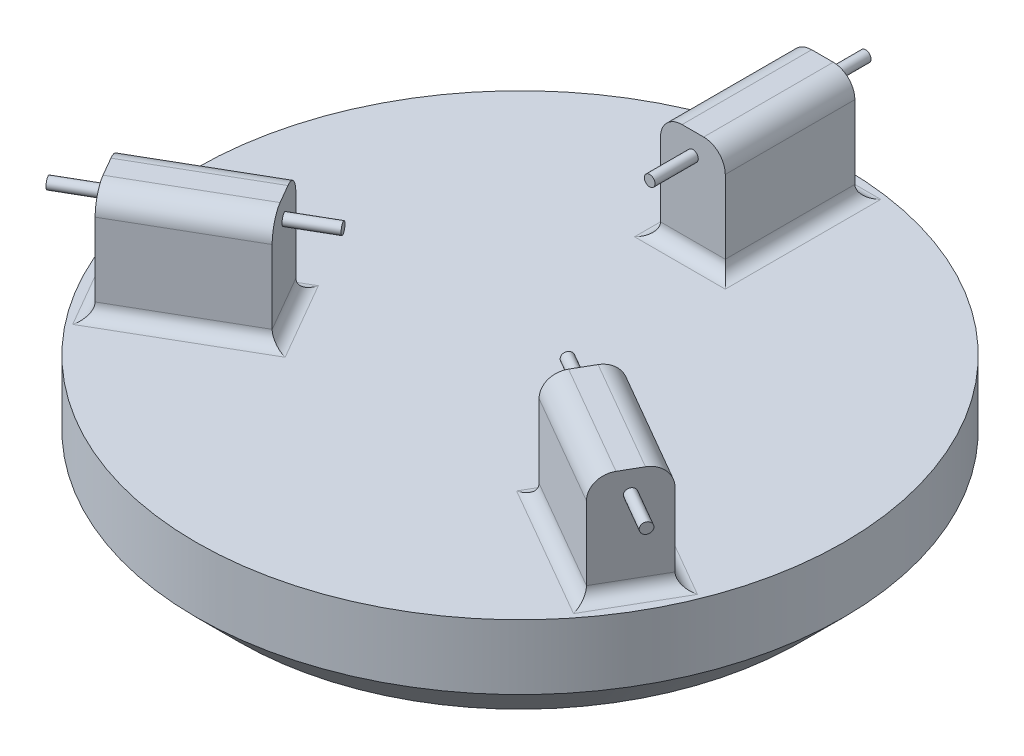
from build123d import *

# Parameters (mm, degrees)
SKETCH1_R           = 75
BOSS_EXTRUDE1_DEPTH = 25
SKETCH2_W           = 15
SKETCH2_H           = 30
BOSS_EXTRUDE2_DEPTH = 25
FILLET1_R           = 3
FILLET2_R           = 5
SKETCH3_R           = 1.25
BOSS_EXTRUDE3_DEPTH = 10
SKETCH4_R           = 1.25
BOSS_EXTRUDE4_DEPTH = 10
SKETCH5_R           = 1.25
BOSS_EXTRUDE5_DEPTH = 10
SKETCH6_R           = 1.25
BOSS_EXTRUDE6_DEPTH = 10
SKETCH7_R           = 1.25
BOSS_EXTRUDE7_DEPTH = 10
SKETCH8_R           = 1.25
BOSS_EXTRUDE8_DEPTH = 10
CHAMFER1_SIZE       = 10


with BuildPart() as part:
    # Sketch1 → Boss-Extrude1 (new body)
    with BuildSketch(Plane(origin=(0, 0, 0), x_dir=(1, 0, 0), z_dir=(0, 1, 0))):
        Circle(SKETCH1_R)
    extrude(amount=BOSS_EXTRUDE1_DEPTH)

    # Sketch2 → Boss-Extrude2 (add)
    with BuildSketch(Plane(origin=(0, 25, 0), x_dir=(1, 0, 0), z_dir=(0, 1, 0))):
        Polygon((-64.371778265, -28.504809472), (-56.871778265, -41.495190528), (-30.891016151, -26.495190528), (-38.391016151, -13.504809472), align=None)
        with Locations((0, 55)):
            Rectangle(SKETCH2_W, SKETCH2_H)
        Polygon((64.371778265, -28.504809472), (56.871778265, -41.495190528), (30.891016151, -26.495190528), (38.391016151, -13.504809472), align=None)
    extrude(amount=BOSS_EXTRUDE2_DEPTH)

    # Fillet1
    fillet1_edges = [part.edges().sort_by_distance(p)[0] for p in [
        (-7.5, 25, -55),
        (0, 25, -40),
        (7.5, 25, -55),
        (0, 25, -70),
        (51.381397208, 25, 21.004809472),
        (34.641016151, 25, 20),
        (43.881397208, 25, 33.995190528),
        (60.621778265, 25, 35),
        (-51.381397208, 25, 21.004809472),
        (-60.621778265, 25, 35),
        (-43.881397208, 25, 33.995190528),
        (-34.641016151, 25, 20),
    ]]
    fillet(fillet1_edges, radius=FILLET1_R)

    # Fillet2
    fillet2_edges = [part.edges().sort_by_distance(p)[0] for p in [
        (-7.5, 50, -55),
        (7.5, 50, -55),
        (51.381397208, 50, 21.004809472),
        (43.881397208, 50, 33.995190528),
        (-51.381397208, 50, 21.004809472),
        (-43.881397208, 50, 33.995190528),
    ]]
    fillet(fillet2_edges, radius=FILLET2_R)

    # Sketch3 → Boss-Extrude3 (add)
    with BuildSketch(Plane(origin=(60.621778265, 0, 35), x_dir=(0.5, 0, -0.866025404), z_dir=(0.866025404, 0, 0.5))):
        with Locations((0, 45)):
            Circle(SKETCH3_R)
    extrude(amount=BOSS_EXTRUDE3_DEPTH)

    # Sketch4 → Boss-Extrude4 (add)
    with BuildSketch(Plane(origin=(34.641016151, 0, 20), x_dir=(-0.5, 0, 0.866025404), z_dir=(-0.866025404, 0, -0.5))):
        with Locations((0, 45)):
            Circle(SKETCH4_R)
    extrude(amount=BOSS_EXTRUDE4_DEPTH)

    # Sketch5 → Boss-Extrude5 (add)
    with BuildSketch(Plane(origin=(0, 0, -70), x_dir=(-1, 0, 0), z_dir=(0, 0, -1))):
        with Locations((0, 45)):
            Circle(SKETCH5_R)
    extrude(amount=BOSS_EXTRUDE5_DEPTH)

    # Sketch6 → Boss-Extrude6 (add)
    with BuildSketch(Plane.XY.offset(-40)):
        with Locations((0, 45)):
            Circle(SKETCH6_R)
    extrude(amount=BOSS_EXTRUDE6_DEPTH)

    # Sketch7 → Boss-Extrude7 (add)
    with BuildSketch(Plane(origin=(-60.621778265, 0, 35), x_dir=(0.5, 0, 0.866025404), z_dir=(-0.866025404, 0, 0.5))):
        with Locations((0, 45)):
            Circle(SKETCH7_R)
    extrude(amount=BOSS_EXTRUDE7_DEPTH)

    # Sketch8 → Boss-Extrude8 (add)
    with BuildSketch(Plane(origin=(-34.641016151, 0, 20), x_dir=(-0.5, 0, -0.866025404), z_dir=(0.866025404, 0, -0.5))):
        with Locations((0, 45)):
            Circle(SKETCH8_R)
    extrude(amount=BOSS_EXTRUDE8_DEPTH)

    # Chamfer1
    chamfer1_edges = [part.edges().sort_by_distance(p)[0] for p in [
        (-75, 0, 0),
    ]]
    chamfer(chamfer1_edges, length=CHAMFER1_SIZE)


solid = part.part
